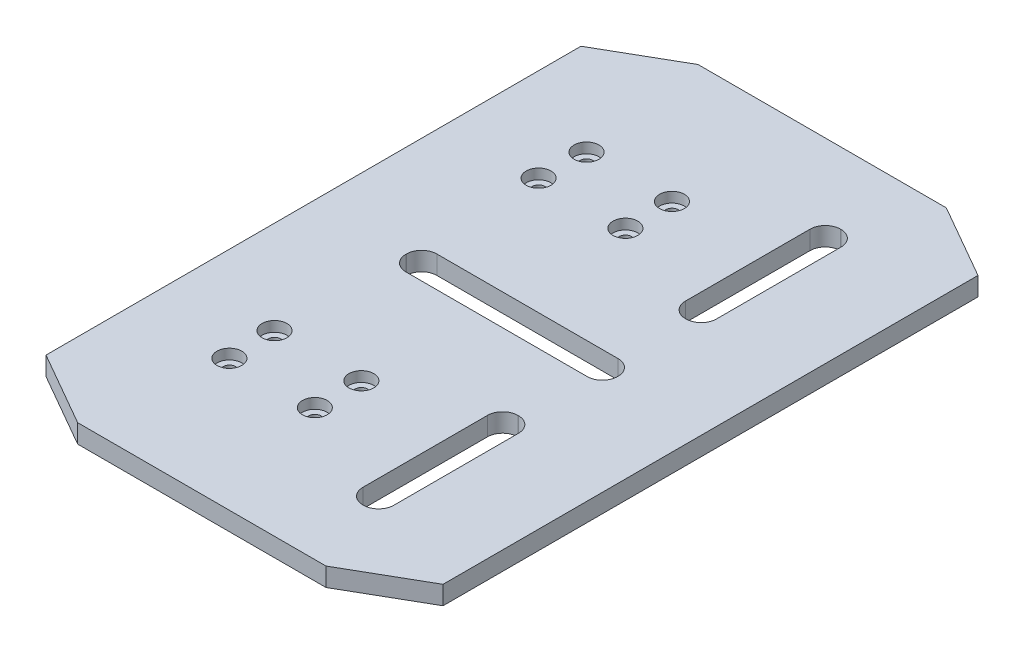
from build123d import *

# Parameters (mm, degrees)
BOSS_EXTRUDE1_DEPTH = 3
CUT_EXTRUDE2_DEPTH  = 10
SKETCH7_R           = 1
CUT_EXTRUDE3_DEPTH  = 11.5
SKETCH8_R           = 2
CUT_EXTRUDE4_DEPTH  = 1.65


with BuildPart() as part:
    # Sketch1 → Boss-Extrude1 (new body)
    with BuildSketch(Plane(origin=(0, 0, 0), x_dir=(1, 0, 0), z_dir=(0, 1, 0))):
        Polygon((-32, -43.117707706), (-20.011895516, -50), (20.011895516, -50), (32, -43.117707706), (32, 43.117707706), (20.011895516, 50), (-20.011895516, 50), (-32, 43.117707706), align=None)
    extrude(amount=BOSS_EXTRUDE1_DEPTH)

    # Sketch5 → Cut-Extrude2 (cut)
    with BuildSketch(Plane(origin=(0, 3, 0), x_dir=(1, 0, 0), z_dir=(0, 1, 0))):
        with BuildLine():
            Line((-14.620176413, -2.5), (14.620176413, -2.5))
            ThreePointArc((14.620176413, -2.5), (16.352588027, -1.782411614), (17.070176413, -0.05))
            Line((17.070176413, -0.05), (17.070176413, 0.05))
            ThreePointArc((17.070176413, 0.05), (16.352588027, 1.782411614), (14.620176413, 2.5))
            Line((14.620176413, 2.5), (-14.620176413, 2.5))
            ThreePointArc((-14.620176413, 2.5), (-16.352588027, 1.782411614), (-17.070176413, 0.05))
            Line((-17.070176413, 0.05), (-17.070176413, -0.05))
            ThreePointArc((-17.070176413, -0.05), (-16.352588027, -1.782411614), (-14.620176413, -2.5))
        make_face()
        with BuildLine():
            Line((14.45, -38.5), (14.55, -38.5))
            ThreePointArc((14.55, -38.5), (16.282411614, -37.782411614), (17, -36.05))
            Line((17, -36.05), (17, -15.95))
            ThreePointArc((17, -15.95), (16.282411614, -14.217588386), (14.55, -13.5))
            Line((14.55, -13.5), (14.45, -13.5))
            ThreePointArc((14.45, -13.5), (12.717588386, -14.217588386), (12, -15.95))
            Line((12, -15.95), (12, -36.05))
            ThreePointArc((12, -36.05), (12.717588386, -37.782411614), (14.45, -38.5))
        make_face()
        with BuildLine():
            Line((14.45, 13.5), (14.55, 13.5))
            ThreePointArc((14.55, 13.5), (16.282411614, 14.217588386), (17, 15.95))
            Line((17, 15.95), (17, 36.05))
            ThreePointArc((17, 36.05), (16.282411614, 37.782411614), (14.55, 38.5))
            Line((14.55, 38.5), (14.45, 38.5))
            ThreePointArc((14.45, 38.5), (12.717588386, 37.782411614), (12, 36.05))
            Line((12, 36.05), (12, 15.95))
            ThreePointArc((12, 15.95), (12.717588386, 14.217588386), (14.45, 13.5))
        make_face()
    extrude(amount=-CUT_EXTRUDE2_DEPTH, mode=Mode.SUBTRACT)

    # Sketch7 → Cut-Extrude3 (cut)
    with BuildSketch(Plane(origin=(0, 3, 0), x_dir=(1, 0, 0), z_dir=(0, 1, 0))):
        with Locations((-3, 28.785)):
            Circle(SKETCH7_R)
        with Locations((-3, 21.285)):
            Circle(SKETCH7_R)
        with Locations((-17, 21.285)):
            Circle(SKETCH7_R)
        with Locations((-16.76760758, 28.785)):
            Circle(SKETCH7_R)
    cut_extrude3 = extrude(amount=-CUT_EXTRUDE3_DEPTH, mode=Mode.SUBTRACT)

    # Mirror1: Cut-Extrude3 across plane
    add(cut_extrude3.mirror(Plane(origin=(0, 0, 0), x_dir=(1, 0, 0), z_dir=(0, 0, -1))), mode=Mode.SUBTRACT)

    # Sketch8 → Cut-Extrude4 (cut)
    with BuildSketch(Plane(origin=(0, 3, 0), x_dir=(1, 0, 0), z_dir=(0, 1, 0))):
        with Locations((-3, -28.785)):
            Circle(SKETCH8_R)
        with Locations((-16.76760758, -28.785)):
            Circle(SKETCH8_R)
        with Locations((-17, -21.285)):
            Circle(SKETCH8_R)
        with Locations((-3, -21.285)):
            Circle(SKETCH8_R)
        with Locations((-3, 28.785)):
            Circle(SKETCH8_R)
        with Locations((-3, 21.285)):
            Circle(SKETCH8_R)
        with Locations((-17, 21.285)):
            Circle(SKETCH8_R)
        with Locations((-16.76760758, 28.785)):
            Circle(SKETCH8_R)
    extrude(amount=-CUT_EXTRUDE4_DEPTH, mode=Mode.SUBTRACT)


solid = part.part
